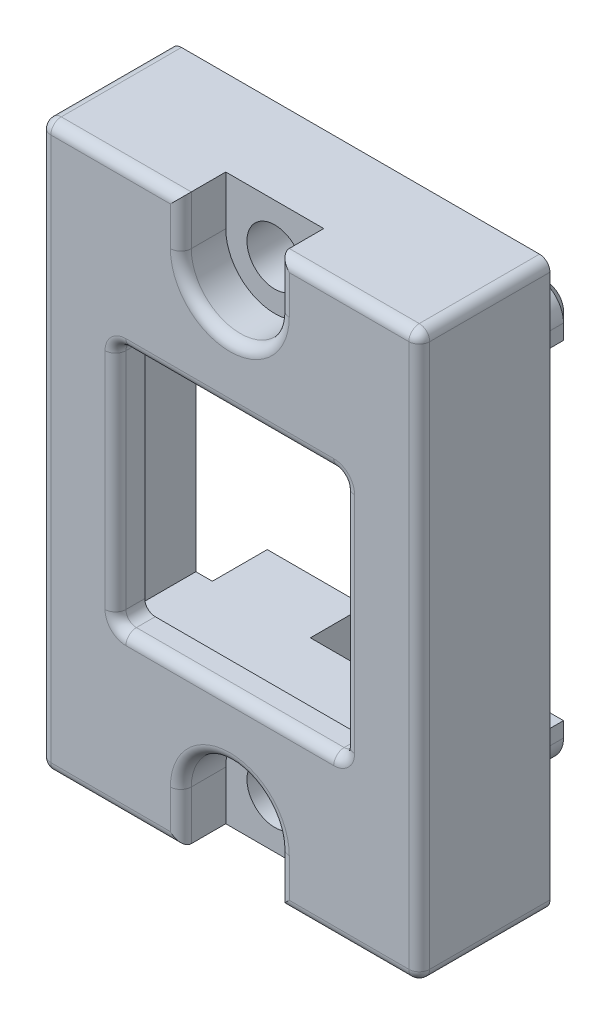
from build123d import *

# Parameters (mm, degrees)
SKETCH1_W                                      = 18.415
SKETCH1_H                                      = 27.432
BOSS_EXTRUDE1_DEPTH                            = 6.35
SKETCH2_W                                      = 11.1125
SKETCH2_H                                      = 11.90625
CUT_EXTRUDE1_DEPTH                             = 7.35
SHELL1_T                                       = -1
BOSS_EXTRUDE2_REACH                            = 8.35
SKETCH5_W                                      = 5.7752
SKETCH5_H                                      = 5.7752
CBORE_FOR_2_SOCKET_HEAD_CAP_SCREW2_D           = 2.7051
CBORE_FOR_2_SOCKET_HEAD_CAP_SCREW2_CBORE_D     = 4.7625
CBORE_FOR_2_SOCKET_HEAD_CAP_SCREW2_CBORE_DEPTH = 2.1844
CUT_EXTRUDE2_DEPTH                             = 4.9276
SKETCH7_W                                      = 11.1125
SKETCH7_H                                      = 11.90625
BOSS_EXTRUDE4_DEPTH                            = 0.4224
SKETCH8_W                                      = 4.7625
SKETCH8_H                                      = 2.3876
CUT_EXTRUDE3_DEPTH                             = 2.1844
FILLET1_R                                      = 0.508
BOSS_EXTRUDE5_REACH                            = 8.35
SKETCH10_W                                     = 16
SKETCH10_H                                     = 16
BOSS_EXTRUDE6_DEPTH                            = 3.175
CHAMFER1_SIZE                                  = 0.508


with BuildPart() as part:
    # Sketch1 → Boss-Extrude1 (new body)
    with BuildSketch(Plane.XY):
        with Locations((73.66, -84.3122297)):
            Rectangle(SKETCH1_W, SKETCH1_H)
    extrude(amount=BOSS_EXTRUDE1_DEPTH)

    # Sketch2 → Cut-Extrude1 (cut, through all)
    with BuildSketch(Plane.XY.offset(6.35)):
        with Locations((73.66, -84.3122297)):
            Rectangle(SKETCH2_W, SKETCH2_H)
    extrude(amount=-CUT_EXTRUDE1_DEPTH, mode=Mode.SUBTRACT)

    # Shell1
    shell1_openings = [part.faces().sort_by_distance(p)[0] for p in [
        (73.66, -90.2653547, 3.175),
        (68.10375, -84.3122297, 3.175),
        (73.66, -78.3591047, 3.175),
        (79.21625, -84.3122297, 3.175),
        (73.66, -84.3122297, 0),
    ]]
    offset(amount=SHELL1_T, openings=shell1_openings, kind=Kind.INTERSECTION)

    # Sketch5 → Boss-Extrude2 (add, up to next)
    with BuildSketch(Plane(origin=(0, 0, 0), x_dir=(-1, 0, 0), z_dir=(0, 0, -1)), mode=Mode.PRIVATE) as boss_extrude2_sk1:
        with Locations((-73.66, -73.4838297)):
            Rectangle(SKETCH5_W, SKETCH5_H)
    boss_extrude2_tool1 = extrude(boss_extrude2_sk1.sketch, amount=-BOSS_EXTRUDE2_REACH, mode=Mode.PRIVATE) - part.part
    add(boss_extrude2_tool1.solids().sort_by_distance((73.66, -73.48383, 0))[0])
    # Sketch5 → Boss-Extrude2 (add, up to next)
    with BuildSketch(Plane(origin=(0, 0, 0), x_dir=(-1, 0, 0), z_dir=(0, 0, -1)), mode=Mode.PRIVATE) as boss_extrude2_sk2:
        with Locations((-73.66, -95.1406297)):
            Rectangle(SKETCH5_W, SKETCH5_H)
    boss_extrude2_tool2 = extrude(boss_extrude2_sk2.sketch, amount=-BOSS_EXTRUDE2_REACH, mode=Mode.PRIVATE) - part.part
    add(boss_extrude2_tool2.solids().sort_by_distance((73.66, -95.14063, 0))[0])

    # CBORE for #2 Socket Head Cap Screw2 (through all)
    with Locations(Plane.XY.offset(6.35)):
        with Locations((73.66, -95.6406297), (73.66, -72.9838297)):
            CounterBoreHole(CBORE_FOR_2_SOCKET_HEAD_CAP_SCREW2_D / 2, CBORE_FOR_2_SOCKET_HEAD_CAP_SCREW2_CBORE_D / 2, CBORE_FOR_2_SOCKET_HEAD_CAP_SCREW2_CBORE_DEPTH)

    # Sketch6 → Cut-Extrude2 (cut)
    with BuildSketch(Plane(origin=(0, 0, 0), x_dir=(-1, 0, 0), z_dir=(0, 0, -1))):
        with BuildLine():
            Line((-76.5476, -95.6406297), (-76.8016, -95.6406297))
            Line((-76.8016, -95.6406297), (-76.8016, -92.2530297))
            Line((-76.8016, -92.2530297), (-70.5184, -92.2530297))
            Line((-70.5184, -92.2530297), (-70.5184, -95.6406297))
            Line((-70.5184, -95.6406297), (-70.7724, -95.6406297))
            ThreePointArc((-70.7724, -95.6406297), (-73.66, -92.7530297), (-76.5476, -95.6406297))
        make_face()
        with BuildLine():
            Line((-76.8016, -72.9838297), (-76.8016, -76.3714297))
            Line((-76.8016, -76.3714297), (-70.5184, -76.3714297))
            Line((-70.5184, -76.3714297), (-70.5184, -72.9838297))
            Line((-70.5184, -72.9838297), (-70.7724, -72.9838297))
            ThreePointArc((-70.7724, -72.9838297), (-73.66, -75.8714297), (-76.5476, -72.9838297))
            Line((-76.5476, -72.9838297), (-76.8016, -72.9838297))
        make_face()
    extrude(amount=-CUT_EXTRUDE2_DEPTH, mode=Mode.SUBTRACT)

    # Sketch7 → Boss-Extrude4 (add)
    with BuildSketch(Plane(origin=(0, 0, 5.35), x_dir=(-1, 0, 0), z_dir=(0, 0, -1))):
        Polygon((-70.7724, -76.3714297), (-76.5476, -76.3714297), (-76.5476, -71.5962297), (-81.8675, -71.5962297), (-81.8675, -97.0282297), (-76.5476, -97.0282297), (-76.5476, -92.2530297), (-70.7724, -92.2530297), (-70.7724, -97.0282297), (-65.4525, -97.0282297), (-65.4525, -71.5962297), (-70.7724, -71.5962297), align=None)
        with Locations((-73.66, -84.3122297)):
            Rectangle(SKETCH7_W, SKETCH7_H, mode=Mode.SUBTRACT)
    extrude(amount=BOSS_EXTRUDE4_DEPTH)

    # Sketch8 → Cut-Extrude3 (cut)
    with BuildSketch(Plane.XY.offset(6.35)):
        with Locations((73.66, -96.8344297)):
            Rectangle(SKETCH8_W, SKETCH8_H)
        with Locations((73.66, -71.7900297)):
            Rectangle(SKETCH8_W, SKETCH8_H)
    extrude(amount=-CUT_EXTRUDE3_DEPTH, mode=Mode.SUBTRACT)

    # Fillet1
    fillet1_edges = [part.edges().sort_by_distance(p)[0] for p in [
        (79.454375, -70.5962297, 6.35),
        (73.66, -93.2593797, 6.35),
        (64.4525, -84.3122297, 6.35),
        (79.21625, -90.2653547, 5.6388),
        (68.10375, -90.2653547, 5.6388),
        (68.10375, -78.3591047, 5.6388),
        (79.21625, -78.3591047, 5.6388),
        (73.66, -90.2653547, 6.35),
        (79.21625, -84.3122297, 6.35),
        (73.66, -78.3591047, 6.35),
        (68.10375, -84.3122297, 6.35),
        (79.454375, -98.0282297, 6.35),
        (76.04125, -96.8344297, 6.35),
        (71.27875, -96.8344297, 6.35),
        (73.66, -75.3650797, 6.35),
        (67.865625, -70.5962297, 6.35),
        (71.27875, -71.7900297, 6.35),
        (76.04125, -71.7900297, 6.35),
        (67.865625, -98.0282297, 6.35),
        (82.8675, -84.3122297, 6.35),
        (64.4525, -98.0282297, 3.175),
        (64.4525, -70.5962297, 3.175),
        (82.8675, -70.5962297, 3.175),
        (82.8675, -98.0282297, 3.175),
    ]]
    fillet(fillet1_edges, radius=FILLET1_R)

    # Sketch10 → Boss-Extrude5 (add, up to next)
    with BuildSketch(Plane(origin=(0, 0, 0), x_dir=(-1, 0, 0), z_dir=(0, 0, -1)), mode=Mode.PRIVATE) as boss_extrude5_sk1:
        with BuildLine():
            Line((-76.5476, -97.0282297), (-76.5476, -95.6406297))
            ThreePointArc((-76.5476, -95.6406297), (-73.66, -92.7530297), (-70.7724, -95.6406297))
            Line((-70.7724, -95.6406297), (-70.7724, -97.0282297))
            Line((-70.7724, -97.0282297), (-65.4525, -97.0282297))
            Line((-65.4525, -97.0282297), (-65.4525, -71.5962297))
            Line((-65.4525, -71.5962297), (-70.7724, -71.5962297))
            Line((-70.7724, -71.5962297), (-70.7724, -72.9838297))
            ThreePointArc((-70.7724, -72.9838297), (-73.66, -75.8714297), (-76.5476, -72.9838297))
            Line((-76.5476, -72.9838297), (-76.5476, -71.5962297))
            Line((-76.5476, -71.5962297), (-81.8675, -71.5962297))
            Line((-81.8675, -71.5962297), (-81.8675, -97.0282297))
            Line((-81.8675, -97.0282297), (-76.5476, -97.0282297))
        make_face()
        with Locations((-73.66, -84.3122297)):
            Rectangle(SKETCH10_W, SKETCH10_H, mode=Mode.SUBTRACT)
    boss_extrude5_tool1 = extrude(boss_extrude5_sk1.sketch, amount=-BOSS_EXTRUDE5_REACH, mode=Mode.PRIVATE) - part.part
    add(boss_extrude5_tool1.solids().sort_by_distance((76.850294, -72.29003, 0))[0])

    # Sketch11 → Boss-Extrude6 (add)
    with BuildSketch(Plane(origin=(0, 0, 0), x_dir=(-1, 0, 0), z_dir=(0, 0, -1))):
        with BuildLine():
            Line((-66.461462743, -92.3122297), (-66.461462743, -93.0447297))
            ThreePointArc((-66.461462743, -93.0447297), (-66.85203585, -93.987656593), (-67.794962743, -94.3782297))
            Line((-67.794962743, -94.3782297), (-71.223962743, -94.3782297))
            Line((-71.223962743, -94.3782297), (-71.223962743, -92.3122297))
            Line((-71.223962743, -92.3122297), (-66.461462743, -92.3122297))
        make_face()
        with BuildLine():
            Line((-76.096037257, -92.3122297), (-80.858537257, -92.3122297))
            Line((-80.858537257, -92.3122297), (-80.858537257, -93.0447297))
            ThreePointArc((-80.858537257, -93.0447297), (-80.46796415, -93.987656593), (-79.525037257, -94.3782297))
            Line((-79.525037257, -94.3782297), (-76.096037257, -94.3782297))
            Line((-76.096037257, -94.3782297), (-76.096037257, -92.3122297))
        make_face()
        with BuildLine():
            Line((-80.858537257, -76.3122297), (-80.858537257, -75.5797297))
            ThreePointArc((-80.858537257, -75.5797297), (-80.46796415, -74.636802807), (-79.525037257, -74.2462297))
            Line((-79.525037257, -74.2462297), (-76.096037257, -74.2462297))
            Line((-76.096037257, -74.2462297), (-76.096037257, -76.3122297))
            Line((-76.096037257, -76.3122297), (-80.858537257, -76.3122297))
        make_face()
        with BuildLine():
            Line((-71.223962743, -76.3122297), (-66.461462743, -76.3122297))
            Line((-66.461462743, -76.3122297), (-66.461462743, -75.5797297))
            ThreePointArc((-66.461462743, -75.5797297), (-66.85203585, -74.636802807), (-67.794962743, -74.2462297))
            Line((-67.794962743, -74.2462297), (-71.223962743, -74.2462297))
            Line((-71.223962743, -74.2462297), (-71.223962743, -76.3122297))
        make_face()
    extrude(amount=BOSS_EXTRUDE6_DEPTH)

    # Chamfer1
    chamfer1_edges = [part.edges().sort_by_distance(p)[0] for p in [
        (68.842712743, -92.3122297, -3.175),
        (71.223962743, -93.3452297, -3.175),
        (69.509462743, -94.3782297, -3.175),
        (66.85203585, -93.987656593, -3.175),
        (66.461462743, -92.6784797, -3.175),
        (80.858537257, -92.6784797, -3.175),
        (80.46796415, -93.987656593, -3.175),
        (77.810537257, -94.3782297, -3.175),
        (76.096037257, -93.3452297, -3.175),
        (78.477287257, -92.3122297, -3.175),
        (80.46796415, -74.636802807, -3.175),
        (80.858537257, -75.9459797, -3.175),
        (78.477287257, -76.3122297, -3.175),
        (76.096037257, -75.2792297, -3.175),
        (77.810537257, -74.2462297, -3.175),
        (66.461462743, -75.9459797, -3.175),
        (66.85203585, -74.636802807, -3.175),
        (69.509462743, -74.2462297, -3.175),
        (71.223962743, -75.2792297, -3.175),
        (68.842712743, -76.3122297, -3.175),
    ]]
    chamfer(chamfer1_edges, length=CHAMFER1_SIZE)


solid = part.part
